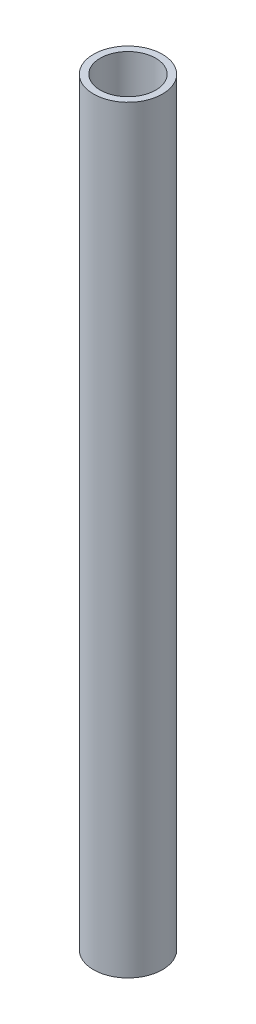
from build123d import *

# Parameters (mm, degrees)
SKETCH1_R           = 6.35
SKETCH1_R_2         = 5.1054
BOSS_EXTRUDE1_DEPTH = 139.7


with BuildPart() as part:
    # Sketch1 → Boss-Extrude1 (new body)
    with BuildSketch(Plane(origin=(0, 0, 0), x_dir=(1, 0, 0), z_dir=(0, 1, 0))):
        Circle(SKETCH1_R)
        Circle(SKETCH1_R_2, mode=Mode.SUBTRACT)
    extrude(amount=BOSS_EXTRUDE1_DEPTH)


solid = part.part
